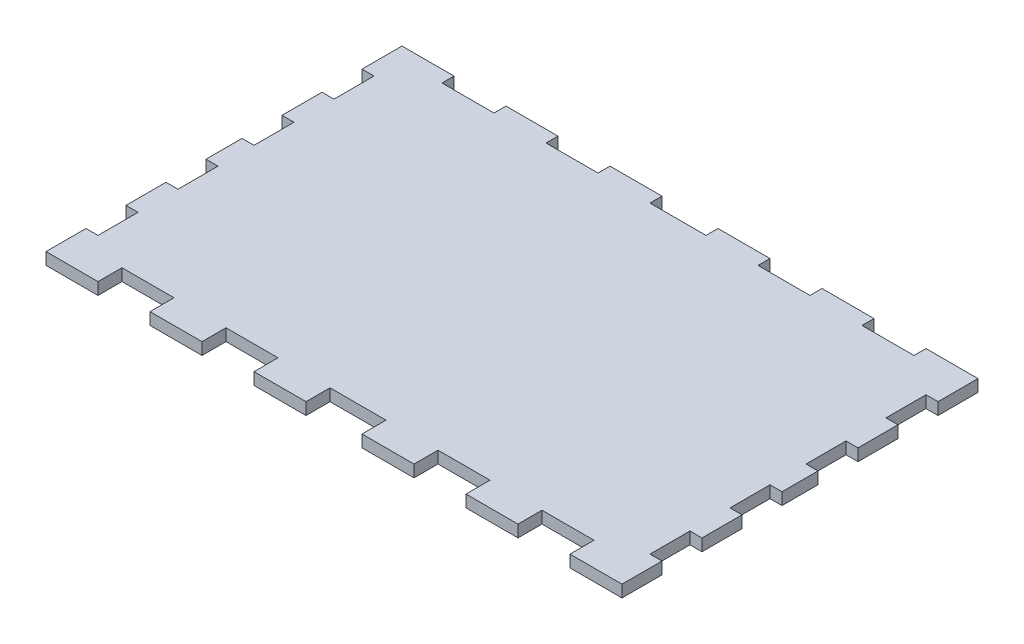
from build123d import *

# Parameters (mm, degrees)
BOSS_EXTRUDE1_DEPTH = 3


with BuildPart() as part:
    # Sketch1 → Boss-Extrude1 (new body)
    with BuildSketch(Plane(origin=(0, 0, 0), x_dir=(1, 0, 0), z_dir=(0, 1, 0))):
        Polygon((26, 89), (39, 89), (39, 86), (52, 86), (52, 89), (65, 89), (65, 86), (79, 86), (79, 89), (92, 89), (92, 86), (105, 86), (105, 89), (118, 89), (118, 86), (131, 86), (131, 89), (144, 89), (144, 79), (141, 79), (141, 69), (144, 69), (144, 59), (141, 59), (141, 49), (144, 49), (144, 40), (141, 40), (141, 30), (144, 30), (144, 20), (141, 20), (141, 10), (144, 10), (144, 0), (131, 0), (131, 6), (118, 6), (118, 0), (105, 0), (105, 6), (92, 6), (92, 0), (79, 0), (79, 6), (65, 6), (65, 0), (52, 0), (52, 6), (39, 6), (39, 0), (26, 0), (26, 6), (13, 6), (13, 0), (0, 0), (0, 10), (3, 10), (3, 20), (0, 20), (0, 30), (3, 30), (3, 40), (0, 40), (0, 49), (3, 49), (3, 59), (0, 59), (0, 69), (3, 69), (3, 79), (0, 79), (0, 89), (13, 89), (13, 86), (26, 86), align=None)
    extrude(amount=BOSS_EXTRUDE1_DEPTH)


solid = part.part
